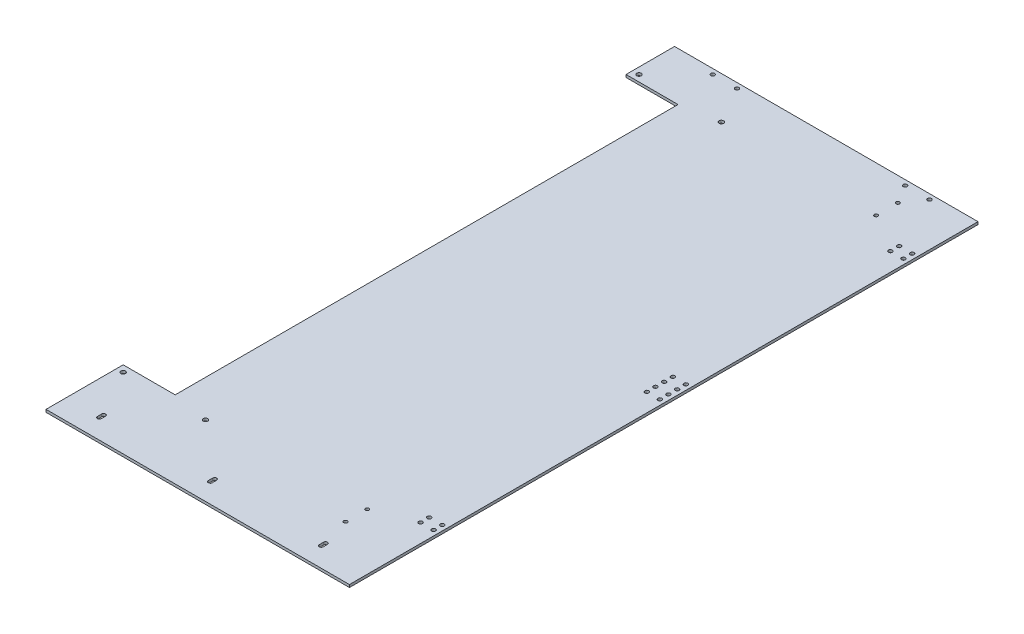
from build123d import *

# Parameters (mm, degrees)
SKETCH_1_W          = 350
SKETCH_1_H          = 3
EXTRUDE_1_DEPTH     = 725
SKETCH_2_R          = 2.6
SKETCH_2_R_2        = 2.25
SKETCH_2_R_3        = 2.05
SKETCH_2_W          = 60
SKETCH_2_H          = 580
CUT_EXTRUDE_1_DEPTH = 10


with BuildPart() as part:
    # 草图1 → 凸台-拉伸1 (new body)
    with BuildSketch(Plane.XY):
        with Locations((156.473684211, 4.735473664)):
            Rectangle(SKETCH_1_W, SKETCH_1_H)
    extrude(amount=EXTRUDE_1_DEPTH)

    # 草图2 → 切除-拉伸1 (cut)
    with BuildSketch(Plane(origin=(0, 6.235473664, 0), x_dir=(1, 0, 0), z_dir=(0, 1, 0))):
        with Locations((-11.026315789, -48.5)):
            Circle(SKETCH_2_R)
        with Locations((83.973684211, -48.5)):
            Circle(SKETCH_2_R)
        with Locations((-11.026315789, -643.5)):
            Circle(SKETCH_2_R)
        with Locations((83.973684211, -643.5)):
            Circle(SKETCH_2_R)
        with Locations((325.473684211, -341)):
            Circle(SKETCH_2_R_2)
        with Locations((310.473684211, -341)):
            Circle(SKETCH_2_R_2)
        with Locations((310.473684211, -331)):
            Circle(SKETCH_2_R_2)
        with Locations((325.473684211, -331)):
            Circle(SKETCH_2_R_2)
        with Locations((310.473684211, -80)):
            Circle(SKETCH_2_R_2)
        with Locations((310.473684211, -70)):
            Circle(SKETCH_2_R_2)
        with Locations((325.473684211, -70)):
            Circle(SKETCH_2_R_2)
        with Locations((325.473684211, -80)):
            Circle(SKETCH_2_R_2)
        with Locations((281.473684211, -6)):
            Circle(SKETCH_2_R_2)
        with Locations((253.473684211, -6)):
            Circle(SKETCH_2_R_2)
        with Locations((31.473684211, -6)):
            Circle(SKETCH_2_R_2)
        with Locations((59.473684211, -6)):
            Circle(SKETCH_2_R_2)
        with Locations((325.473684211, -351)):
            Circle(SKETCH_2_R_2)
        with Locations((310.473684211, -351)):
            Circle(SKETCH_2_R_2)
        with Locations((325.473684211, -361)):
            Circle(SKETCH_2_R_2)
        with Locations((310.473684211, -361)):
            Circle(SKETCH_2_R_2)
        with Locations((310.473684211, -612)):
            Circle(SKETCH_2_R_2)
        with Locations((325.473684211, -612)):
            Circle(SKETCH_2_R_2)
        with Locations((325.473684211, -622)):
            Circle(SKETCH_2_R_2)
        with Locations((310.473684211, -622)):
            Circle(SKETCH_2_R_2)
        with Locations((266.473684211, -639.5)):
            Circle(SKETCH_2_R_3)
        with Locations((266.473684211, -664.5)):
            Circle(SKETCH_2_R_3)
        with Locations((266.473684211, -52.5)):
            Circle(SKETCH_2_R_3)
        with Locations((266.473684211, -27.5)):
            Circle(SKETCH_2_R_3)
        with Locations((11.473684211, -346)):
            Rectangle(SKETCH_2_W, SKETCH_2_H)
        with BuildLine():
            Line((18.223684211, -702.5), (18.223684211, -697.5))
            ThreePointArc((18.223684211, -697.5), (20.473684211, -695.25), (22.723684211, -697.5))
            Line((22.723684211, -697.5), (22.723684211, -702.5))
            ThreePointArc((22.723684211, -702.5), (20.473684211, -704.75), (18.223684211, -702.5))
        make_face()
        with BuildLine():
            Line((150.723684211, -702.5), (150.723684211, -697.5))
            ThreePointArc((150.723684211, -697.5), (148.473684211, -695.25), (146.223684211, -697.5))
            Line((146.223684211, -697.5), (146.223684211, -702.5))
            ThreePointArc((146.223684211, -702.5), (148.473684211, -704.75), (150.723684211, -702.5))
        make_face()
        with BuildLine():
            Line((278.723684211, -702.5), (278.723684211, -697.5))
            ThreePointArc((278.723684211, -697.5), (276.473684211, -695.25), (274.223684211, -697.5))
            Line((274.223684211, -697.5), (274.223684211, -702.5))
            ThreePointArc((274.223684211, -702.5), (276.473684211, -704.75), (278.723684211, -702.5))
        make_face()
    extrude(amount=-CUT_EXTRUDE_1_DEPTH, mode=Mode.SUBTRACT)


solid = part.part
